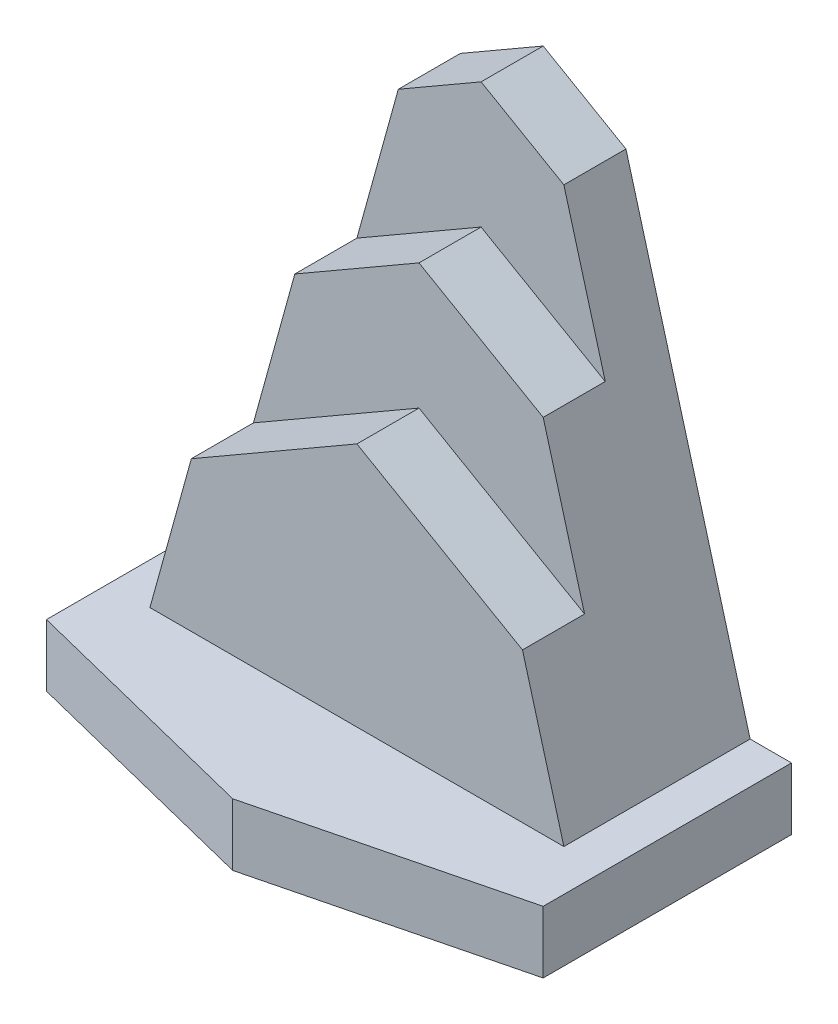
from build123d import *

# Parameters (mm, degrees)
EXTRUDE1_DEPTH = 15
EXTRUDE2_DEPTH = 15
EXTRUDE3_DEPTH = 15
EXTRUDE4_DEPTH = 15


with BuildPart() as part:
    # Sketch1 → Extrude1 (new body)
    with BuildSketch(Plane(origin=(0, 0, 0), x_dir=(1, 0, 0), z_dir=(0, 1, 0))):
        Polygon((0, 0), (-60, -15), (-120, 0), (-120, 60), (0, 60), align=None)
    extrude(amount=EXTRUDE1_DEPTH)

    # Sketch2 → Extrude2 (add)
    with BuildSketch(Plane(origin=(0, 0, -60), x_dir=(-1, 0, 0), z_dir=(0, 0, -1))):
        Polygon((110, 15), (80, 123.452994616), (60, 135), (40, 123.452994616), (10, 15), align=None)
    extrude(amount=-EXTRUDE2_DEPTH)

    # Sketch3 → Extrude3 (add)
    with BuildSketch(Plane.XY.offset(-45)):
        Polygon((-10, 15), (-30, 87.301996411), (-60, 104.622504486), (-90, 87.301996411), (-110, 15), align=None)
    extrude(amount=EXTRUDE3_DEPTH)

    # Sketch4 → Extrude4 (add)
    with BuildSketch(Plane.XY.offset(-30)):
        Polygon((-110, 15), (-10, 15), (-20, 51.150998205), (-60, 74.245008973), (-100, 51.150998205), align=None)
    extrude(amount=EXTRUDE4_DEPTH)


solid = part.part
